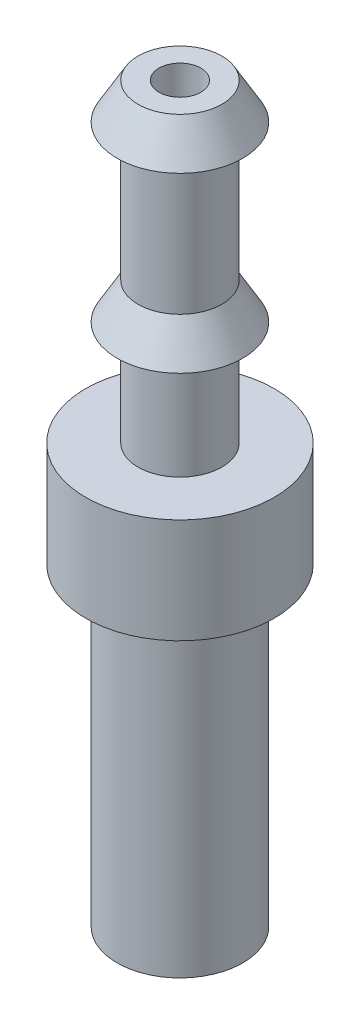
from build123d import *


with BuildPart() as part:
    # Эскиз1 → Повернуть1 (revolve)
    with BuildSketch(Plane.XY):
        Polygon((-1, -15), (-3, -15), (-3, 0), (-4.5, 0), (-4.5, 5), (-2, 5), (-2, 10), (-3, 10), (-2, 11.732050808), (-2, 18.267949192), (-3, 18.267949192), (-2, 20), (-1, 20), align=None)
    revolve(axis=Axis((0, 0, 0), (0, 1, 0)))


solid = part.part
